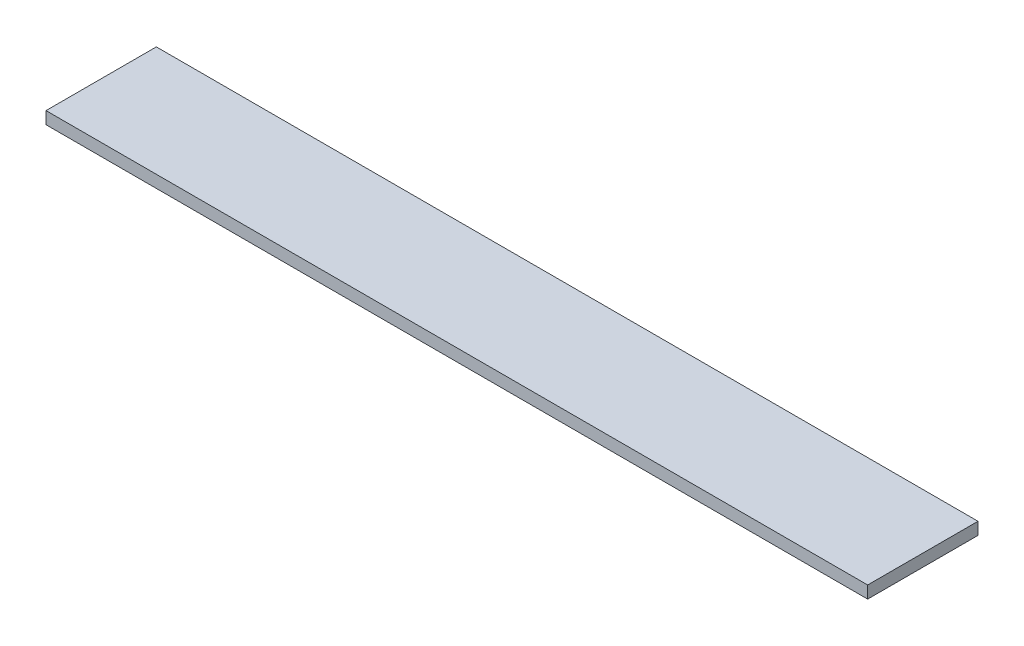
from build123d import *

# Parameters (mm, degrees)
SKETCH1_W           = 201.06
SKETCH1_H           = 27
BOSS_EXTRUDE1_DEPTH = 3


with BuildPart() as part:
    # Sketch1 → Boss-Extrude1 (new body)
    with BuildSketch(Plane(origin=(0, 0, 0), x_dir=(1, 0, 0), z_dir=(0, 1, 0))):
        Rectangle(SKETCH1_W, SKETCH1_H)
    extrude(amount=-BOSS_EXTRUDE1_DEPTH)


solid = part.part
